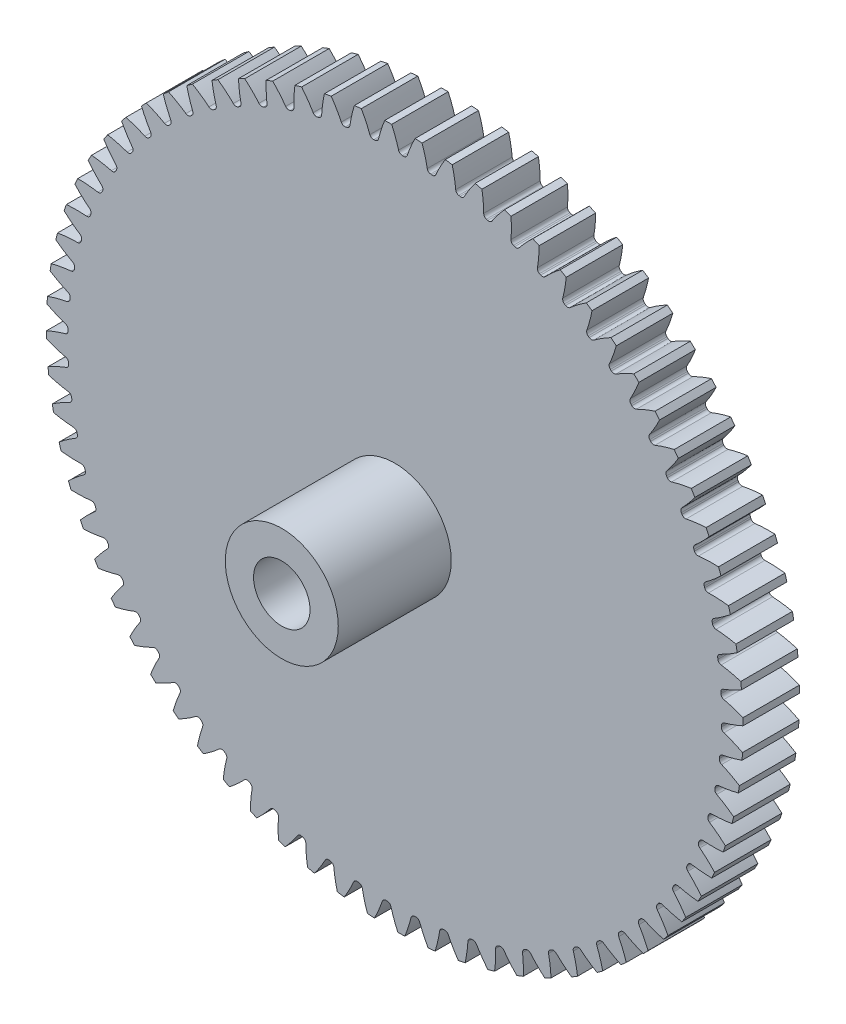
from build123d import *

# Parameters (mm, degrees)
SKETCH3_R           = 19.579166667
GEARBODY_DEPTH      = 3.175
TOOTHCUT_DEPTH      = 4.175
CIRPATTERN1_COUNT   = 72
BOREDIA_R           = 3.175
BORE_DEPTH          = 12700
SKETCH4_R           = 3.175
BOSS_EXTRUDE1_DEPTH = 6.35
SKETCH5_R           = 1.5875
CUT_EXTRUDE1_DEPTH  = 6.35


with BuildPart() as part:
    # Sketch3 → gearBody (new body)
    with BuildSketch(Plane.XY):
        Circle(SKETCH3_R)
    extrude(amount=GEARBODY_DEPTH)

    # Sketch2 → toothCut (cut, through all)
    with BuildSketch(Plane.XY):
        with BuildLine():
            ThreePointArc((18.357573992, -0.493273508), (18.358568508, -0.454757041), (18.359482212, -0.416238572))
            ThreePointArc((18.359482212, -0.416238572), (18.40447107, -0.289650345), (18.515975652, -0.214715006))
            ThreePointArc((18.515975652, -0.214715006), (20.816655163, 0.890214559), (22.599606758, 2.716434472))
            ThreePointArc((22.599606758, 2.716434472), (22.75529654, -0.563667658), (22.437395624, -3.832038552))
            ThreePointArc((22.437395624, -3.832038552), (20.747049203, -1.919782153), (18.503897812, -0.70229811))
            ThreePointArc((18.503897812, -0.70229811), (18.396240129, -0.621933939), (18.357573992, -0.493273508))
        make_face()
    toothcut = extrude(amount=TOOTHCUT_DEPTH, mode=Mode.SUBTRACT)

    # CirPattern1: toothCut ×72 about axis
    cirpattern1_axis = Axis((0, 0, 0), (0, 0, 1))
    for i in range(1, CIRPATTERN1_COUNT):
        add(toothcut.rotate(cirpattern1_axis, i * 360 / CIRPATTERN1_COUNT), mode=Mode.SUBTRACT)

    # boreDia → bore (cut, symmetric)
    with BuildSketch(Plane.XY):
        Circle(BOREDIA_R)
    extrude(amount=BORE_DEPTH, both=True, mode=Mode.SUBTRACT)


with BuildPart() as body_2:
    # Sketch4 → Boss-Extrude1 (new body)
    with BuildSketch(Plane.XY.offset(3.175)):
        Circle(SKETCH4_R)
    extrude(amount=BOSS_EXTRUDE1_DEPTH)

    # Sketch5 → Cut-Extrude1 (cut)
    with BuildSketch(Plane.XY.offset(9.525)):
        Circle(SKETCH5_R)
    extrude(amount=-CUT_EXTRUDE1_DEPTH, mode=Mode.SUBTRACT)


solid = Compound([part.part, body_2.part])
